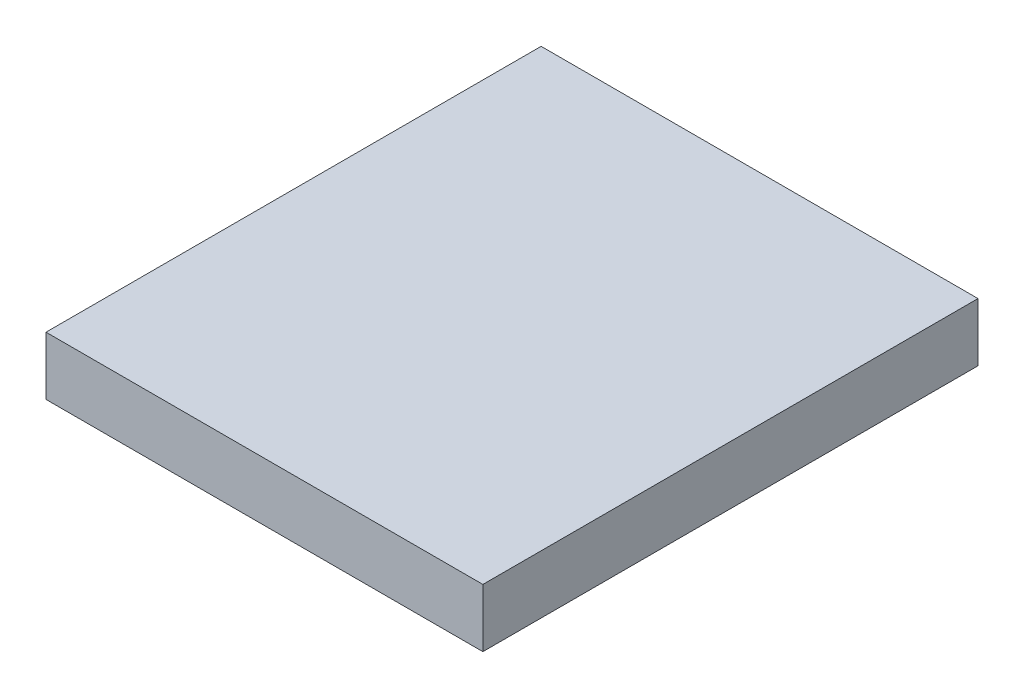
from build123d import *

# Parameters (mm, degrees)
SKETCH1_W           = 190.5
SKETCH1_H           = 215.9
BOSS_EXTRUDE1_DEPTH = 25.4


with BuildPart() as part:
    # Sketch1 → Boss-Extrude1 (new body)
    with BuildSketch(Plane(origin=(0, 0, 0), x_dir=(1, 0, 0), z_dir=(0, 1, 0))):
        Rectangle(SKETCH1_W, SKETCH1_H)
    extrude(amount=BOSS_EXTRUDE1_DEPTH)


solid = part.part
